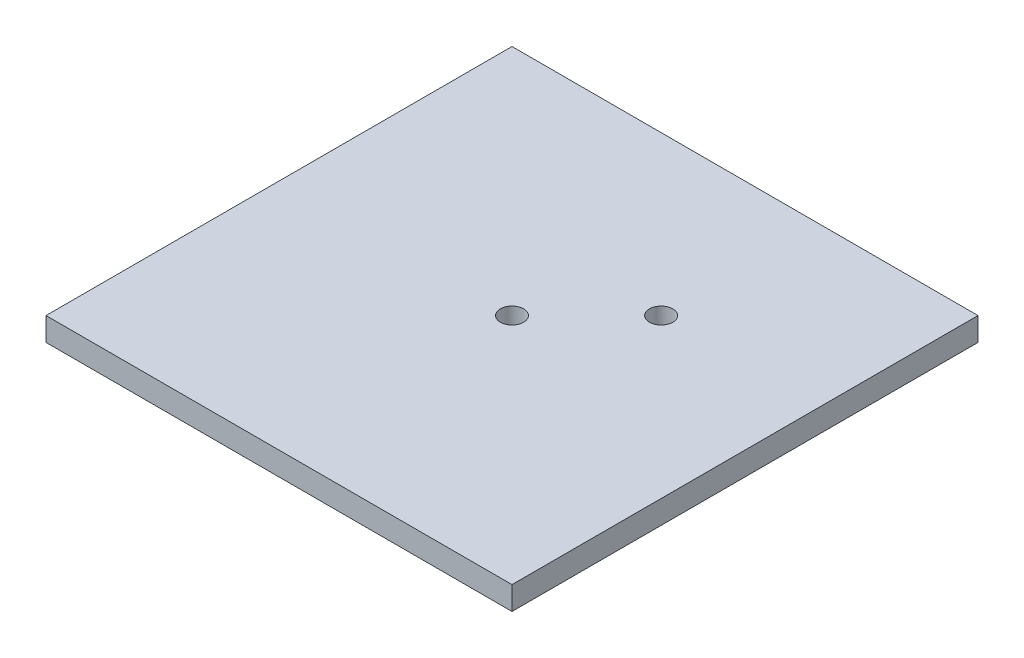
from build123d import *

# Parameters (mm, degrees)
SKETCH_1_W      = 100
SKETCH_1_H      = 100
SKETCH_1_R      = 2.5
EXTRUDE_1_DEPTH = 5


with BuildPart() as part:
    # 草图1 → 凸台-拉伸1 (new body)
    with BuildSketch(Plane(origin=(0, 0, 0), x_dir=(1, 0, 0), z_dir=(0, 1, 0))):
        Rectangle(SKETCH_1_W, SKETCH_1_H)
        Circle(SKETCH_1_R, mode=Mode.SUBTRACT)
        with Locations((16, 16)):
            Circle(SKETCH_1_R, mode=Mode.SUBTRACT)
    extrude(amount=EXTRUDE_1_DEPTH)


solid = part.part
